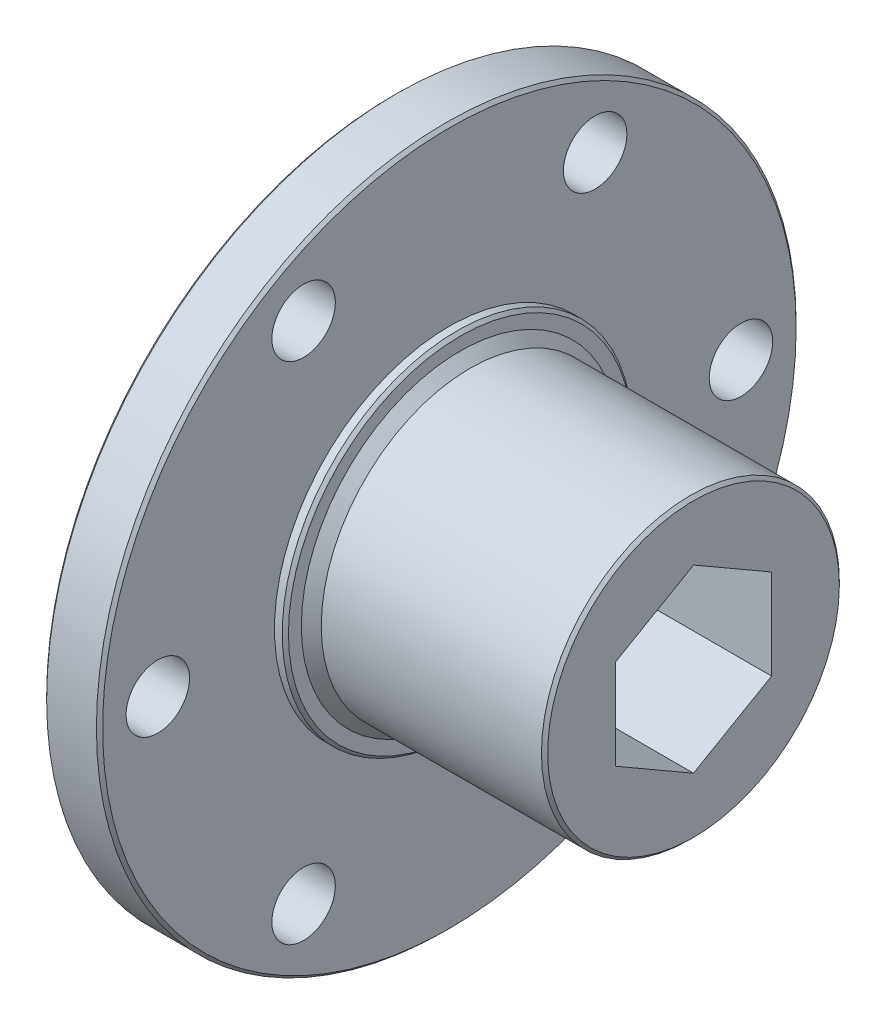
from build123d import *

# Parameters (mm, degrees)
SKETCH1_W           = 4.572
SKETCH1_H           = 28.575
SKETCH2_R           = 14.2875
BOSS_EXTRUDE1_DEPTH = 0.889
SKETCH3_R           = 12.9794
BOSS_EXTRUDE2_DEPTH = 0.8128
BOSS_EXTRUDE2_TAPER = 45
SKETCH4_R           = 12.1666
BOSS_EXTRUDE3_DEPTH = 18.2372
SKETCH5_R           = 14.2875
BOSS_EXTRUDE4_DEPTH = 0.889
CUT_EXTRUDE1_DEPTH  = 26.4
HOLE1_D             = 5.1816
HOLE1_DEPTH         = 24.511
CHAMFER1_SIZE       = 0.254


with BuildPart() as part:
    # Sketch1 → Revolve1 (revolve)
    with BuildSketch(Plane(origin=(0, 0, 0), x_dir=(-1, 0, 0), z_dir=(0, 0, -1))):
        with Locations((16.210066246, 14.2875)):
            Rectangle(SKETCH1_W, SKETCH1_H)
    revolve(axis=Axis((-13.924066246, 0, 0), (-1, 0, 0)))

    # Sketch2 → Boss-Extrude1 (add)
    with BuildSketch(Plane(origin=(-13.924066246, 0, 0), x_dir=(0, 0, -1), z_dir=(1, 0, 0))):
        Circle(SKETCH2_R)
    extrude(amount=BOSS_EXTRUDE1_DEPTH)

    # Sketch3 → Boss-Extrude2 (add)
    with BuildSketch(Plane(origin=(-13.035066246, 0, 0), x_dir=(0, 0, -1), z_dir=(1, 0, 0))):
        Circle(SKETCH3_R)
    extrude(amount=BOSS_EXTRUDE2_DEPTH, taper=BOSS_EXTRUDE2_TAPER)

    # Sketch4 → Boss-Extrude3 (add)
    with BuildSketch(Plane(origin=(-12.222266246, 0, 0), x_dir=(0, 0, -1), z_dir=(1, 0, 0))):
        Circle(SKETCH4_R)
    extrude(amount=BOSS_EXTRUDE3_DEPTH)

    # Sketch5 → Boss-Extrude4 (add)
    with BuildSketch(Plane.ZY.offset(18.496066246)):
        Circle(SKETCH5_R)
    extrude(amount=BOSS_EXTRUDE4_DEPTH)

    # Sketch6 → Cut-Extrude1 (cut, through all)
    with BuildSketch(Plane.ZY.offset(19.385066246)):
        Polygon((0, 7.361657812), (-6.3754, 3.680818906), (-6.3754, -3.680858906), (0, -7.361697812), (6.3754, -3.680858906), (6.3754, 3.680818906), align=None)
    extrude(amount=-CUT_EXTRUDE1_DEPTH, mode=Mode.SUBTRACT)

    # Hole1
    with Locations(Plane.ZY.offset(18.496066246)):
        with Locations((11.90625, 20.622229928), (-23.8125, 0), (11.90625, -20.622229928), (-11.90625, -20.622229928), (-11.90625, 20.622229928), (23.8125, 0)):
            Hole(HOLE1_D / 2, depth=HOLE1_DEPTH)

    # Chamfer1
    chamfer1_edges = [part.edges().sort_by_distance(p)[0] for p in [
        (6.014933754, 0, 12.1666),
        (-19.385066246, 0, -14.2875),
        (-18.496066246, -28.575, 0),
        (-13.924066246, -28.575, 0),
        (-13.035066246, 0, 14.2875),
    ]]
    chamfer(chamfer1_edges, length=CHAMFER1_SIZE)


solid = part.part
